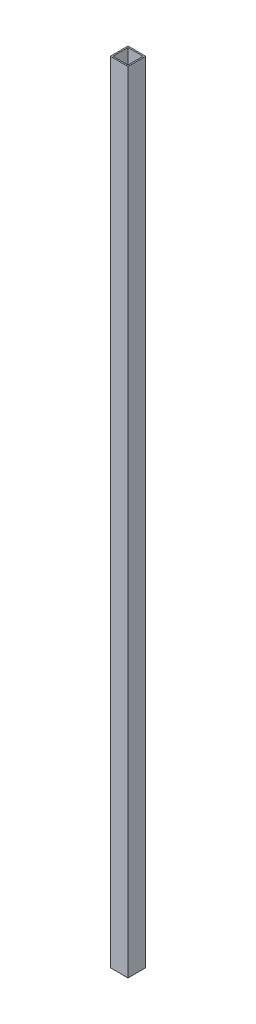
from build123d import *

# Parameters (mm, degrees)
SKETCH1_W           = 44.45
SKETCH1_H           = 44.45
SKETCH1_W_2         = 38.1
SKETCH1_H_2         = 38.1
BOSS_EXTRUDE1_DEPTH = 1981.2


with BuildPart() as part:
    # Sketch1 → Boss-Extrude1 (new body)
    with BuildSketch(Plane(origin=(0, 0, 0), x_dir=(1, 0, 0), z_dir=(0, 1, 0))):
        with Locations((22.225, 22.225)):
            Rectangle(SKETCH1_W, SKETCH1_H)
        with Locations((22.225, 22.225)):
            Rectangle(SKETCH1_W_2, SKETCH1_H_2, mode=Mode.SUBTRACT)
    extrude(amount=BOSS_EXTRUDE1_DEPTH)


solid = part.part
